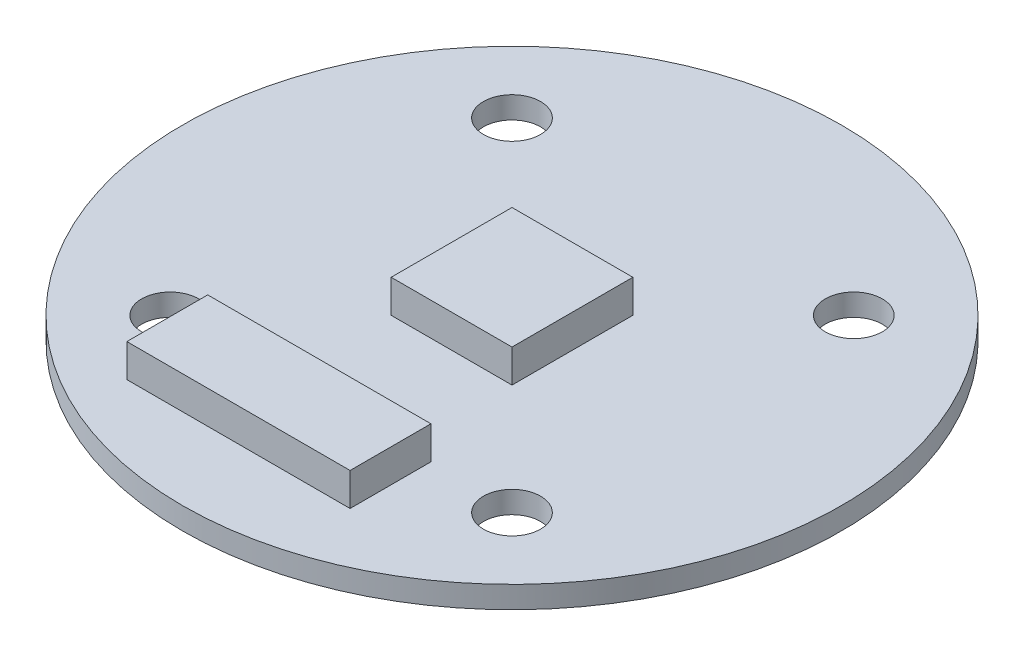
from build123d import *

# Parameters (mm, degrees)
SKETCH_1_R      = 15
SKETCH_1_R_2    = 1.3
EXTRUDE_2_DEPTH = 1
SKETCH_2_W      = 5.5
SKETCH_2_H      = 5.5
SKETCH_2_W_2    = 10.16
SKETCH_2_H_2    = 3.68
EXTRUDE_5_DEPTH = 1.5
SKETCH_3_W      = 5
SKETCH_3_H      = 3.37
EXTRUDE_7_DEPTH = 1.5


with BuildPart() as part:
    # 草图1 → 凸台-拉伸2 (new body)
    with BuildSketch(Plane(origin=(0, 0, 0), x_dir=(1, 0, 0), z_dir=(0, 1, 0))):
        Circle(SKETCH_1_R)
        with Locations((-7.778174593, 7.778174593)):
            Circle(SKETCH_1_R_2, mode=Mode.SUBTRACT)
        with Locations((7.778174593, 7.778174593)):
            Circle(SKETCH_1_R_2, mode=Mode.SUBTRACT)
        with Locations((7.778174593, -7.778174593)):
            Circle(SKETCH_1_R_2, mode=Mode.SUBTRACT)
        with Locations((-7.778174593, -7.778174593)):
            Circle(SKETCH_1_R_2, mode=Mode.SUBTRACT)
    extrude(amount=EXTRUDE_2_DEPTH)

    # 草图2 → 凸台-拉伸5 (add)
    with BuildSketch(Plane(origin=(0, 1, 0), x_dir=(1, 0, 0), z_dir=(0, 1, 0))):
        Rectangle(SKETCH_2_W, SKETCH_2_H)
        with Locations((-1.15, -9.46)):
            Rectangle(SKETCH_2_W_2, SKETCH_2_H_2)
    extrude(amount=EXTRUDE_5_DEPTH)

    # 草图3 → 凸台-拉伸7 (add)
    with BuildSketch(Plane.XZ):
        Rectangle(SKETCH_3_W, SKETCH_3_H)
    extrude(amount=EXTRUDE_7_DEPTH)


solid = part.part
